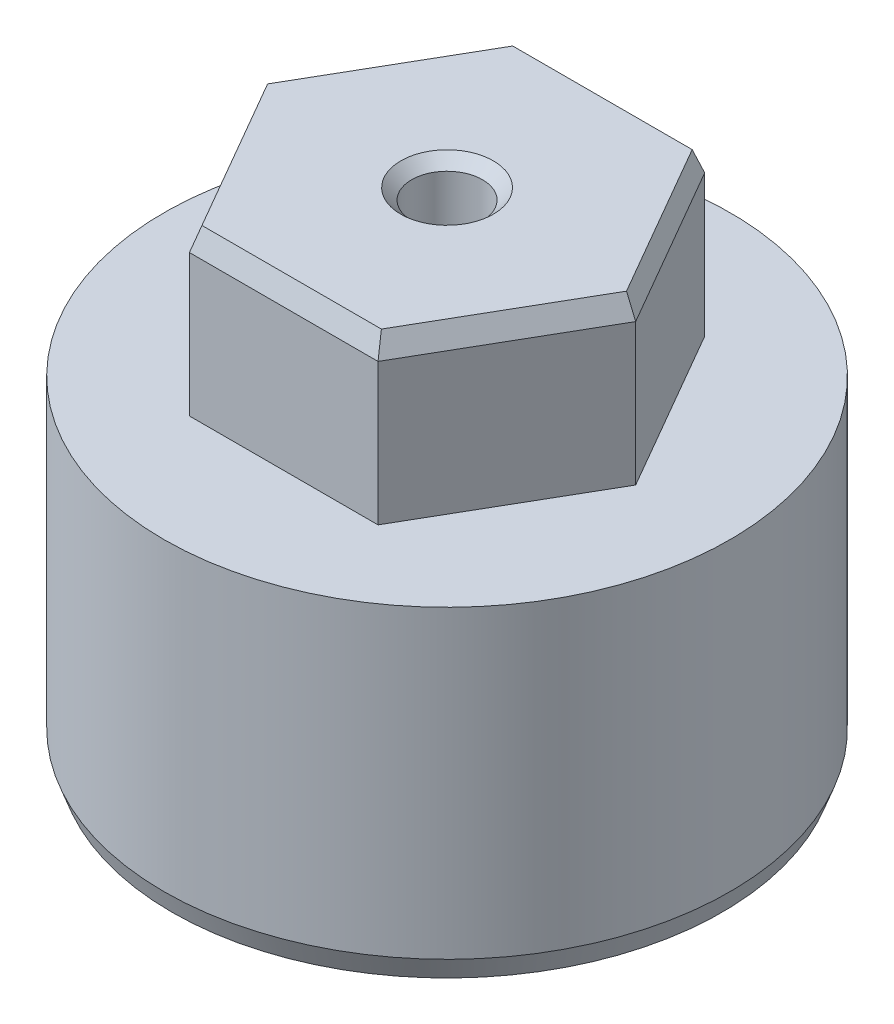
from build123d import *

# Parameters (mm, degrees)
SKETCH1_R             = 26
BOSS_EXTRUDE1_DEPTH   = 15
BOSS_EXTRUDE2_DEPTH   = 15
CHAMFER1_SIZE         = 2
CHAMFER1_SIZE2        = 0.727940469
CHAMFER1_PART_2_SIZE  = 2
CHAMFER1_PART_2_SIZE2 = 0.727940469
CHAMFER1_PART_3_SIZE  = 2
CHAMFER1_PART_3_SIZE2 = 0.727940469
CHAMFER1_PART_4_SIZE  = 2
CHAMFER1_PART_4_SIZE2 = 0.727940469
CHAMFER1_PART_5_SIZE  = 2
CHAMFER1_PART_5_SIZE2 = 0.727940469
CHAMFER1_PART_6_SIZE  = 2
CHAMFER1_PART_6_SIZE2 = 0.727940469
CHAMFER2_SIZE         = 2
CHAMFER2_SIZE2        = 0.727940469
SKETCH3_R             = 3.25
CUT_EXTRUDE1_DEPTH    = 18
CHAMFER3_SIZE         = 1


with BuildPart() as part:
    # Sketch1 → Boss-Extrude1 (new body, symmetric)
    with BuildSketch(Plane(origin=(0, 0, 0), x_dir=(1, 0, 0), z_dir=(0, 1, 0))):
        Circle(SKETCH1_R)
    extrude(amount=BOSS_EXTRUDE1_DEPTH, both=True)

    # Sketch2 → Boss-Extrude2 (add)
    with BuildSketch(Plane(origin=(0, 15, 0), x_dir=(1, 0, 0), z_dir=(0, 1, 0))):
        Polygon((-17.320508076, 0), (-8.660254038, -15), (8.660254038, -15), (17.320508076, 0), (8.660254038, 15), (-8.660254038, 15), align=None)
    extrude(amount=BOSS_EXTRUDE2_DEPTH)

    # Chamfer1
    chamfer1_edges = [part.edges().sort_by_distance(p)[0] for p in [
        (-12.990381057, 30, -7.5),
    ]]
    chamfer1_side = [part.faces().sort_by_distance(p)[0] for p in [
        (-12.990381057, 22.5, -7.5),
    ]]
    chamfer(chamfer1_edges, length=CHAMFER1_SIZE, length2=CHAMFER1_SIZE2, reference=chamfer1_side[0])

    # Chamfer1 part 2
    chamfer1_part_2_edges = [part.edges().sort_by_distance(p)[0] for p in [
        (-12.990381057, 30, 7.5),
    ]]
    chamfer1_part_2_side = [part.faces().sort_by_distance(p)[0] for p in [
        (-12.990381057, 22.5, 7.5),
    ]]
    chamfer(chamfer1_part_2_edges, length=CHAMFER1_PART_2_SIZE, length2=CHAMFER1_PART_2_SIZE2, reference=chamfer1_part_2_side[0])

    # Chamfer1 part 3
    chamfer1_part_3_edges = [part.edges().sort_by_distance(p)[0] for p in [
        (0, 30, 15),
    ]]
    chamfer1_part_3_side = [part.faces().sort_by_distance(p)[0] for p in [
        (0, 22.5, 15),
    ]]
    chamfer(chamfer1_part_3_edges, length=CHAMFER1_PART_3_SIZE, length2=CHAMFER1_PART_3_SIZE2, reference=chamfer1_part_3_side[0])

    # Chamfer1 part 4
    chamfer1_part_4_edges = [part.edges().sort_by_distance(p)[0] for p in [
        (12.990381057, 30, 7.5),
    ]]
    chamfer1_part_4_side = [part.faces().sort_by_distance(p)[0] for p in [
        (12.990381057, 22.5, 7.5),
    ]]
    chamfer(chamfer1_part_4_edges, length=CHAMFER1_PART_4_SIZE, length2=CHAMFER1_PART_4_SIZE2, reference=chamfer1_part_4_side[0])

    # Chamfer1 part 5
    chamfer1_part_5_edges = [part.edges().sort_by_distance(p)[0] for p in [
        (12.990381057, 30, -7.5),
    ]]
    chamfer1_part_5_side = [part.faces().sort_by_distance(p)[0] for p in [
        (12.990381057, 22.5, -7.5),
    ]]
    chamfer(chamfer1_part_5_edges, length=CHAMFER1_PART_5_SIZE, length2=CHAMFER1_PART_5_SIZE2, reference=chamfer1_part_5_side[0])

    # Chamfer1 part 6
    chamfer1_part_6_edges = [part.edges().sort_by_distance(p)[0] for p in [
        (0, 30, -15),
    ]]
    chamfer1_part_6_side = [part.faces().sort_by_distance(p)[0] for p in [
        (0, 22.5, -15),
    ]]
    chamfer(chamfer1_part_6_edges, length=CHAMFER1_PART_6_SIZE, length2=CHAMFER1_PART_6_SIZE2, reference=chamfer1_part_6_side[0])

    # Chamfer2
    chamfer2_edges = [part.edges().sort_by_distance(p)[0] for p in [
        (-26, -15, 0),
    ]]
    chamfer2_side = [part.faces().sort_by_distance(p)[0] for p in [
        (-26, 0, 0),
    ]]
    chamfer(chamfer2_edges, length=CHAMFER2_SIZE, length2=CHAMFER2_SIZE2, reference=chamfer2_side[0])

    # Sketch3 → Cut-Extrude1 (cut)
    with BuildSketch(Plane(origin=(0, 30, 0), x_dir=(1, 0, 0), z_dir=(0, 1, 0))):
        Circle(SKETCH3_R)
    extrude(amount=-CUT_EXTRUDE1_DEPTH, mode=Mode.SUBTRACT)

    # Chamfer3
    chamfer3_edges = [part.edges().sort_by_distance(p)[0] for p in [
        (-3.25, 30, 0),
    ]]
    chamfer(chamfer3_edges, length=CHAMFER3_SIZE)


solid = part.part
